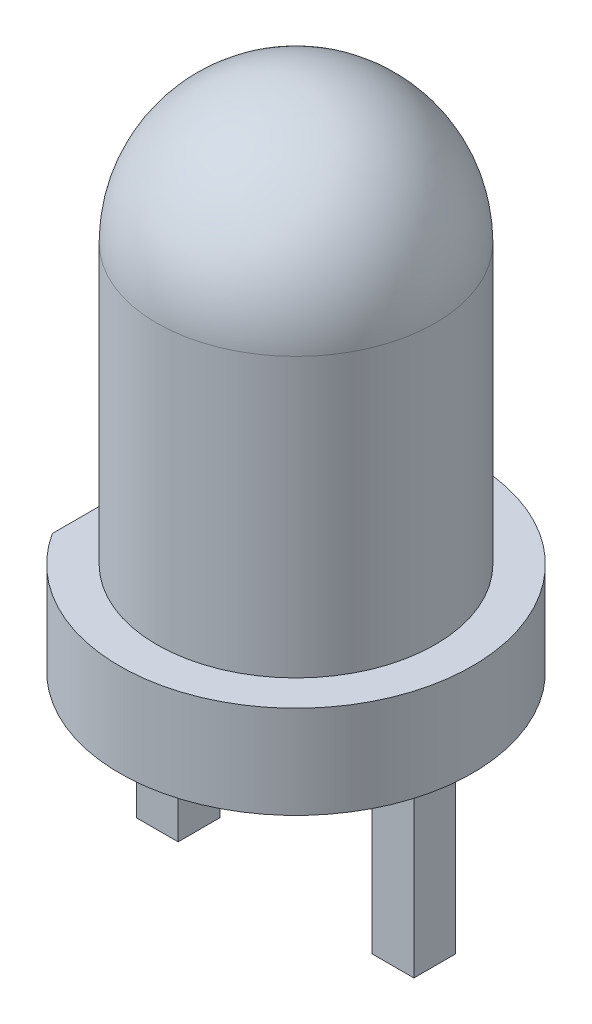
from build123d import *

# Parameters (mm, degrees)
BOSS_EXTRUDE1_DEPTH             = 0.225
BOSS_EXTRUDE1_2_DEPTH           = 0.225
SKETCH5_W                       = 0.3
SKETCH5_H                       = 0.3
BOSS_EXTRUDE2_DEPTH             = 0.1
BOSS_EXTRUDE2_DIRECTION_2_REACH = 6.503
CUT_EXTRUDE1_DEPTH              = 1
BODY_MOVE_COPY1_ANGLE           = 90


with BuildPart() as part:
    # Sketch2 → Boss-Extrude1 (new, symmetric)
    with BuildSketch(Plane(origin=(0, 0, 0), x_dir=(0, 0, -1), z_dir=(1, 0, 0))):
        Polygon((1.045, -1.8), (1.495, -1.8), (1.495, 1.09), (1.395, 1.19), (1.395, 2.39), (-0.795, 2.39), (-0.795, 1.99), (0.005, 1.19), (0.755, 1.19), (1.045, 0.9), align=None)
    extrude(amount=BOSS_EXTRUDE1_DEPTH, both=True)

    # Sketch3 → Revolve1 (revolve)
    with BuildSketch(Plane(origin=(0, 0, 0), x_dir=(0, 0, -1), z_dir=(1, 0, 0))):
        with BuildLine():
            Line((0.685, 2.39), (0.6, 2.39))
            Line((0.6, 2.39), (0, 2.09))
            Line((0, 2.09), (0, 1.79))
            Line((0, 1.79), (0.694549996, 2.36343291))
            ThreePointArc((0.694549996, 2.36343291), (0.699115707, 2.380074133), (0.685, 2.39))
        make_face()
        Polygon((0.6, 2.39), (0, 2.39), (0, 2.09), align=None)
    revolve(axis=Axis((0, 0, 0), (0, 1, 0)))

    # Sketch3_5 → Cut-Revolve1 (revolve, cut)
    with BuildSketch(Plane(origin=(0, 0, 0), x_dir=(0, 0, -1), z_dir=(1, 0, 0)), mode=Mode.PRIVATE) as cut_revolve1_sk:
        Polygon((0.6, 2.39), (0, 2.39), (0, 2.09), align=None)
    revolve(cut_revolve1_sk.sketch.rotate(Axis((0, 0, 0), (0, 1, 0)), 180), axis=Axis((0, 0, 0), (0, 1, 0)), mode=Mode.SUBTRACT)

    # Sketch5 → Boss-Extrude2 (add)
    with BuildSketch(Plane(origin=(0, 2.39, 0), x_dir=(1, 0, 0), z_dir=(0, 1, 0))):
        Rectangle(SKETCH5_W, SKETCH5_H)
    extrude(amount=BOSS_EXTRUDE2_DEPTH)

    # Sketch5 → Boss-Extrude2 direction 2 (add, up to next)
    with BuildSketch(Plane(origin=(0, 2.39, 0), x_dir=(1, 0, 0), z_dir=(0, 1, 0)), mode=Mode.PRIVATE) as boss_extrude2_direction_2_sk1:
        Rectangle(SKETCH5_W, SKETCH5_H)
    boss_extrude2_direction_2_tool1 = extrude(boss_extrude2_direction_2_sk1.sketch, amount=-BOSS_EXTRUDE2_DIRECTION_2_REACH, mode=Mode.PRIVATE) - part.part
    add(boss_extrude2_direction_2_tool1.solids().sort_by_distance((0, 2.39, 0))[0])


with BuildPart() as body_2:
    # Sketch2 → Boss-Extrude1 2 (new, symmetric)
    with BuildSketch(Plane(origin=(0, 0, 0), x_dir=(0, 0, -1), z_dir=(1, 0, 0))):
        Polygon((-1.495, -1.8), (-1.045, -1.8), (-1.045, 0.9), (-0.755, 1.19), (-0.495, 1.19), (-0.495, 1.39), (-1.095, 1.99), (-1.095, 2.39), (-1.395, 2.39), (-1.395, 1.19), (-1.495, 1.09), align=None)
    extrude(amount=BOSS_EXTRUDE1_2_DEPTH, both=True)


with BuildPart() as body_3:
    # Sketch6 → Revolve2 (revolve)
    with BuildSketch(Plane(origin=(0, 0, 0), x_dir=(0, 0, -1), z_dir=(1, 0, 0))):
        with BuildLine():
            Line((0, 0.2), (1.9, 0.2))
            Line((1.9, 0.2), (1.9, 1.2))
            Line((1.9, 1.2), (1.5, 1.2))
            Line((1.5, 1.2), (1.5, 4.2))
            ThreePointArc((1.5, 4.2), (1.060660172, 5.260660172), (0, 5.7))
            Line((0, 5.7), (0, 0.2))
        make_face()
    revolve(axis=Axis((0, 0, 0), (0, 1, 0)))

    # Sketch7 → Cut-Extrude1 (cut)
    with BuildSketch(Plane.XZ.offset(-0.2)):
        with BuildLine():
            Line((-1.024695077, -1.6), (1.024695077, -1.6))
            ThreePointArc((1.024695077, -1.6), (0, -1.9), (-1.024695077, -1.6))
        make_face()
    extrude(amount=-CUT_EXTRUDE1_DEPTH, mode=Mode.SUBTRACT)


with BuildPart() as body_2_1:
    # Body-Move_Copy1: moved
    add(body_2.part.rotate(Axis((0, 0, 0), (0, 1, 0)), BODY_MOVE_COPY1_ANGLE))


with BuildPart() as body_3_1:
    # Body-Move_Copy1: moved
    add(body_3.part.rotate(Axis((0, 0, 0), (0, 1, 0)), BODY_MOVE_COPY1_ANGLE))


with BuildPart() as part_1:
    # Body-Move_Copy1: moved
    add(part.part.rotate(Axis((0, 0, 0), (0, 1, 0)), BODY_MOVE_COPY1_ANGLE))


solid = Compound([body_2_1.part, body_3_1.part, part_1.part])
